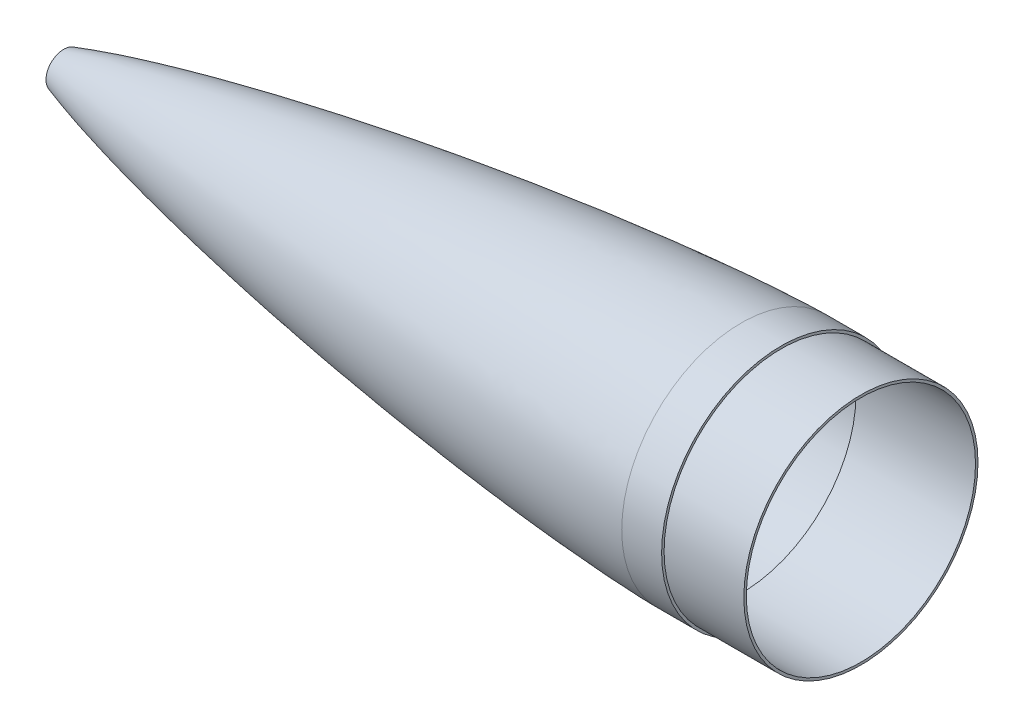
from build123d import *


with BuildPart() as part:
    # Sketch6 → Revolve1 (revolve)
    with BuildSketch(Plane.XY, mode=Mode.PRIVATE) as revolve1_sk:
        with BuildLine():
            Line((50.8, 22.53035676), (50.8, 6.35))
            Line((50.8, 6.35), (53.975, 6.35))
            Line((53.975, 6.35), (53.975, 20.227565916))
            add(Edge.make_bspline(
                [(53.975, 20.227565916), (54.291634879, 20.330430839), (55.162475518, 20.612719168), (56.636149311, 21.087725347), (58.867170376, 21.80102074), (61.522421046, 22.638682883), (64.736507837, 23.637812157), (68.023541536, 24.646609183), (72.39438926, 25.969741612), (77.802325895, 27.573199633), (84.37229967, 29.477097548), (93.118193973, 31.954107645), (108.466778526, 36.165197289), (130.491628823, 41.875745108), (165.870302673, 50.489926314), (210.303076361, 60.449379541), (281.693068548, 75.067985253), (371.347473816, 91.310304544), (479.374979471, 108.229836311), (569.684892552, 120.376775068), (642.076792345, 128.912483065), (696.438363769, 134.692640498), (750.863527692, 139.800693107), (796.267539796, 143.42521879), (832.617797313, 145.860290015), (859.890749047, 147.416222506), (882.628689993, 148.436275801), (898.53412358, 148.946546098), (907.62769622, 149.150954449), (912.14731785, 149.217348506), (914.4107585, 149.225018228)],
                knots=[0.06148136, 0.06148136, 0.06148136, 0.06148136, 0.06256458, 0.064402689, 0.066240798, 0.069917015, 0.073593232, 0.07726945, 0.080945667, 0.088298102, 0.095650536, 0.103002971, 0.11770784, 0.147117579, 0.176527318, 0.235346795, 0.294166272, 0.411805227, 0.529444182, 0.647083136, 0.705902613, 0.764722091, 0.823541568, 0.882361045, 0.911770784, 0.941180523, 0.970590261, 0.985295131, 0.992647565, 1, 1, 1, 1], degree=3))
            Line((914.4107585, 149.225018228), (914.4107585, 146.05))
            Line((914.4107585, 146.05), (1066.8, 146.05))
            Line((1066.8, 146.05), (1066.8, 149.225))
            Line((1066.8, 149.225), (965.2, 149.225))
            Line((965.2, 149.225), (965.2, 152.4))
            Line((965.2, 152.4), (914.4, 152.4))
            add(Edge.make_bspline(
                [(50.8, 22.53035676), (51.62596102, 22.801930188), (53.247366667, 23.331443773), (57.113810342, 24.581671091), (62.137627853, 26.163245596), (68.472923462, 28.113411094), (76.389796689, 30.474842786), (85.386033894, 33.081102875), (95.241355255, 35.841520364), (106.104903016, 38.788706559), (117.812200959, 41.867831442), (130.423899043, 45.08497442), (143.907449646, 48.417167108), (158.285989872, 51.860839853), (172.682057827, 55.208017205), (187.101006341, 58.468808185), (201.536340401, 61.648015415), (215.98908439, 64.751824582), (234.073297096, 68.542392147), (255.802551989, 72.956576003), (281.189453131, 77.92470015), (306.614812158, 82.692611325), (328.432361696, 86.646151134), (350.268122203, 90.497714312), (372.121192631, 94.250003895), (397.640090518, 98.488121242), (426.834492226, 103.147632175), (456.056824987, 107.628600482), (485.305388678, 111.934967932), (514.578772116, 116.069226586), (543.875783343, 120.032588186), (573.19542697, 123.82488003), (602.536868801, 127.444739672), (631.89942018, 130.889153604), (661.282519219, 134.153873932), (698.036524214, 138.001817701), (742.180870702, 142.229994267), (786.373789985, 145.926990276), (830.615211008, 148.98950394), (864.145536025, 150.817451898), (884.93243709, 151.702539519), (900.347440379, 152.177178216), (908.376949057, 152.340862845), (912.39222778, 152.393196617), (914.4, 152.4)],
                knots=[0.058888363, 0.058888363, 0.058888363, 0.058888363, 0.058888363, 0.06286181, 0.066835256, 0.074782149, 0.082729042, 0.090675935, 0.102752696, 0.114829458, 0.126906219, 0.138982981, 0.154876753, 0.170770526, 0.186664299, 0.202558071, 0.218451844, 0.234345618, 0.250239391, 0.266133165, 0.297920711, 0.329708258, 0.361495805, 0.377389579, 0.393283353, 0.4250709, 0.456858447, 0.488645994, 0.52043354, 0.552221087, 0.584008633, 0.615796181, 0.647583729, 0.679371276, 0.711158823, 0.74294637, 0.774733917, 0.838309011, 0.901884107, 0.933671654, 0.965459201, 0.9827296, 0.9913648, 1, 1, 1, 1, 1], degree=4))
        make_face()
    revolve(revolve1_sk.sketch.rotate(Axis((-61.64472501, 0, 0), (1, 0, 0)), 90), axis=Axis((-61.64472501, 0, 0), (1, 0, 0)))


solid = part.part
